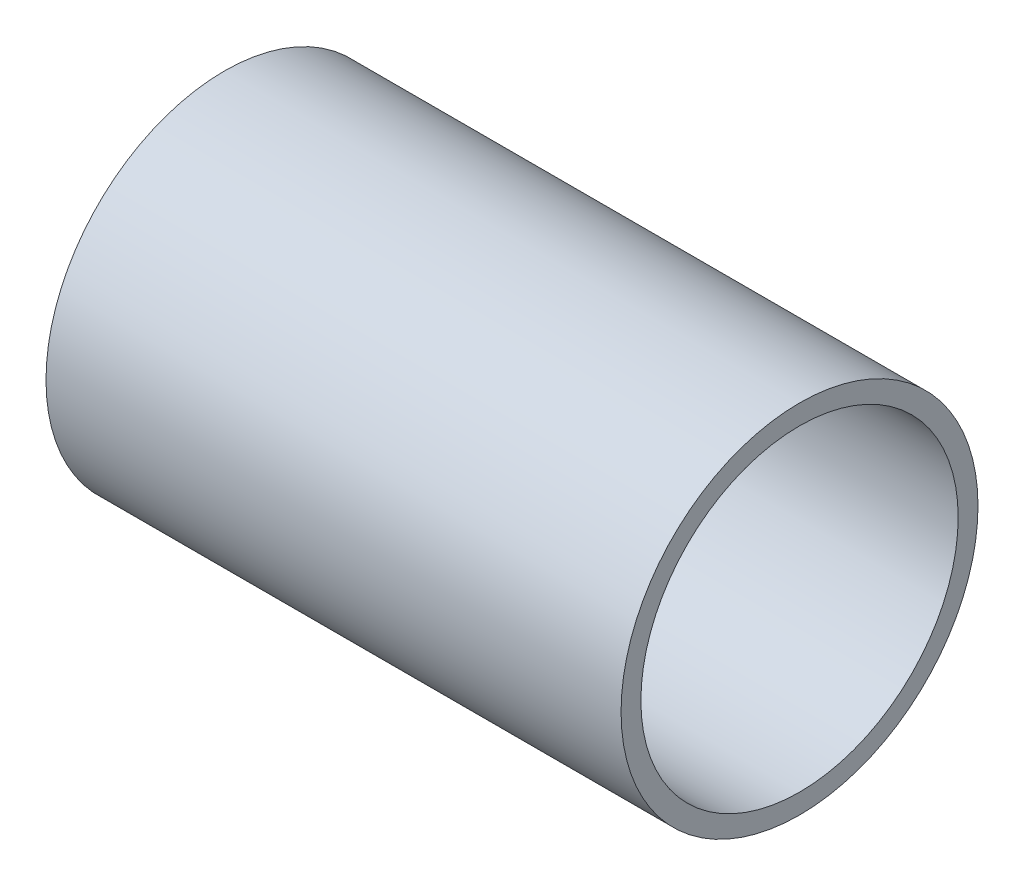
from build123d import *

# Parameters (mm, degrees)
SKETCH1_R           = 45
SKETCH1_R_2         = 40
BOSS_EXTRUDE1_DEPTH = 145


with BuildPart() as part:
    # Sketch1 → Boss-Extrude1 (new body)
    with BuildSketch(Plane(origin=(0, 0, 0), x_dir=(0, 0, -1), z_dir=(1, 0, 0))):
        Circle(SKETCH1_R)
        Circle(SKETCH1_R_2, mode=Mode.SUBTRACT)
    extrude(amount=BOSS_EXTRUDE1_DEPTH)


solid = part.part
